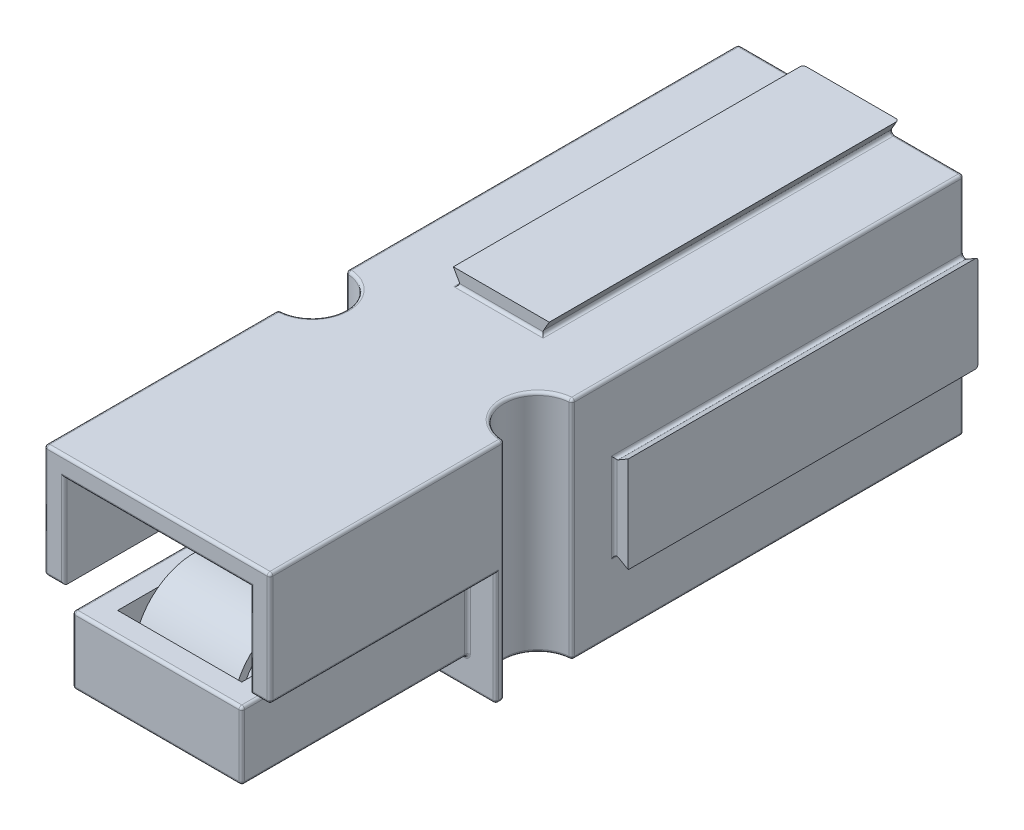
from build123d import *

# Parameters (mm, degrees)
ESQUISSE1_W              = 8.5
ESQUISSE1_H              = 8.5
EXTRUSION1_DEPTH         = 24.6
ESQUISSE6_W              = 3.050497429
ESQUISSE6_H              = 0.5
ESQUISSE6_W_2            = 2.3
ENL_V_MAT_EXTRU_4_DEPTH  = 25.6
ESQUISSE2_W              = 0.5
ESQUISSE2_H              = 2.8
ESQUISSE2_H_2            = 2.3
ENL_V_MAT_EXTRU_1_DEPTH  = 25.6
ESQUISSE4_R              = 1.2
ENL_V_MAT_EXTRU_3_DEPTH  = 9
ESQUISSE11_W             = 3.4
ESQUISSE11_H             = 0.5
ESQUISSE11_W_2           = 0.5
ESQUISSE11_H_2           = 3.4
ENL_V_MAT_EXTRU_9_DEPTH  = 12.2
ENL_V_MAT_EXTRU_5_DEPTH  = 8
ESQUISSE7_W              = 6.6
ESQUISSE7_H              = 3.9
ENL_V_MAT_EXTRU_6_DEPTH  = 8
ESQUISSE8_W              = 5.2
ESQUISSE8_H              = 5.2
ENL_V_MAT_EXTRU_7_DEPTH  = 8
ENL_V_MAT_EXTRU_8_DEPTH  = 13
ENL_V_MAT_EXTRU_10_DEPTH = 12.4
ESQUISSE14_W             = 4.4
ESQUISSE14_H             = 6.4
ENL_V_MAT_EXTRU_11_DEPTH = 1.75
EXTRUSION2_DEPTH         = 1.75
EXTRUSION2_DEPTH_BACK    = 1.75
ESQUISSE15_W             = 4.4
ESQUISSE15_H             = 1.75
ENL_V_MAT_EXTRU_12_DEPTH = 0.8
FILLET1_R                = 0.1
SKETCH1_R                = 2
CUT_EXTRUDE1_DEPTH       = 7.6


with BuildPart() as part:
    # Esquisse1 → Extrusion1 (new body)
    with BuildSketch(Plane.XY):
        Rectangle(ESQUISSE1_W, ESQUISSE1_H)
    extrude(amount=EXTRUSION1_DEPTH)

    # Esquisse6 → Enlèv. mat.-Extru.4 (cut, through all)
    with BuildSketch(Plane.XY.offset(24.6)):
        with Locations((2.975248715, 4)):
            Rectangle(ESQUISSE6_W, ESQUISSE6_H)
        with Locations((-3.1, 4)):
            Rectangle(ESQUISSE6_W_2, ESQUISSE6_H)
    extrude(amount=-ENL_V_MAT_EXTRU_4_DEPTH, mode=Mode.SUBTRACT)

    # Esquisse2 → Enlèv. mat.-Extru.1 (cut, through all)
    with BuildSketch(Plane.XY.offset(24.6)):
        with Locations((4, 2.85)):
            Rectangle(ESQUISSE2_W, ESQUISSE2_H)
        with Locations((4, -3.1)):
            Rectangle(ESQUISSE2_W, ESQUISSE2_H_2)
    extrude(amount=-ENL_V_MAT_EXTRU_1_DEPTH, mode=Mode.SUBTRACT)

    # Esquisse4 → Enlèv. mat.-Extru.3 (cut, through all)
    with BuildSketch(Plane(origin=(0, 3.75, 0), x_dir=(-1, 0, 0), z_dir=(0, 1, 0))):
        with Locations((-3.75, 15.1)):
            Circle(ESQUISSE4_R)
        with Locations((4.25, 15.1)):
            Circle(ESQUISSE4_R)
    extrude(amount=-ENL_V_MAT_EXTRU_3_DEPTH, mode=Mode.SUBTRACT)

    # Esquisse11 → Enlèv. mat.-Extru.9 (cut)
    with BuildSketch(Plane.XY.offset(24.6)):
        with Locations((-0.25, 4)):
            Rectangle(ESQUISSE11_W, ESQUISSE11_H)
        with Locations((4, -0.25)):
            Rectangle(ESQUISSE11_W_2, ESQUISSE11_H_2)
    extrude(amount=-ENL_V_MAT_EXTRU_9_DEPTH, mode=Mode.SUBTRACT)

    # Esquisse5 → Enlèv. mat.-Extru.5 (cut)
    with BuildSketch(Plane.XY.offset(24.6)):
        Polygon((-4.25, -0.25), (-3.25, -0.25), (-3.25, -3.25), (2.75, -3.25), (2.75, -0.25), (3.75, -0.25), (3.75, -4.25), (-4.25, -4.25), align=None)
    extrude(amount=-ENL_V_MAT_EXTRU_5_DEPTH, mode=Mode.SUBTRACT)

    # Esquisse7 → Enlèv. mat.-Extru.6 (cut)
    with BuildSketch(Plane.XY.offset(24.6)):
        with Locations((-0.25, 1.1)):
            Rectangle(ESQUISSE7_W, ESQUISSE7_H)
    extrude(amount=-ENL_V_MAT_EXTRU_6_DEPTH, mode=Mode.SUBTRACT)

    # Esquisse8 → Enlèv. mat.-Extru.7 (cut)
    with BuildSketch(Plane(origin=(0, 0, 0), x_dir=(-1, 0, 0), z_dir=(0, 0, -1))):
        with Locations((0.25, -0.25)):
            Rectangle(ESQUISSE8_W, ESQUISSE8_H)
    extrude(amount=-ENL_V_MAT_EXTRU_7_DEPTH, mode=Mode.SUBTRACT)

    # Esquisse9 → Enlèv. mat.-Extru.8 (cut)
    with BuildSketch(Plane(origin=(0, 0, 0), x_dir=(-1, 0, 0), z_dir=(0, 0, -1))):
        Polygon((-1.45, 4.25), (-1.161324865, 3.75), (-1.45, 3.75), align=None)
        Polygon((1.95, 3.75), (1.95, 4.25), (1.661324865, 3.75), align=None)
        Polygon((-4.25, 1.45), (-3.75, 1.161324865), (-3.75, 1.45), align=None)
        Polygon((-3.75, -1.95), (-4.25, -1.95), (-3.75, -1.661324865), align=None)
    extrude(amount=-ENL_V_MAT_EXTRU_8_DEPTH, mode=Mode.SUBTRACT)

    # Esquisse12 → Enlèv. mat.-Extru.10 (cut)
    with BuildSketch(Plane(origin=(0, 0, 0), x_dir=(-1, 0, 0), z_dir=(0, 0, -1))):
        Polygon((4.25, 1.161324865), (4.25, -1.661324865), (3.75, -1.95), (3.75, 1.45), align=None)
        Polygon((-1.161324865, -4.25), (1.661324865, -4.25), (1.95, -3.75), (-1.45, -3.75), align=None)
    extrude(amount=-ENL_V_MAT_EXTRU_10_DEPTH, mode=Mode.SUBTRACT)

    # Esquisse14 → Enlèv. mat.-Extru.11 (cut)
    with BuildSketch(Plane(origin=(0, -0.85, 0), x_dir=(-1, 0, 0), z_dir=(0, 1, 0))):
        with Locations((0.25, 20.6)):
            Rectangle(ESQUISSE14_W, ESQUISSE14_H)
    extrude(amount=-ENL_V_MAT_EXTRU_11_DEPTH, mode=Mode.SUBTRACT)

    # Esquisse13 → Extrusion2 (add, two sides)
    with BuildSketch(Plane(origin=(-0.25, 0, 0), x_dir=(0, 0, -1), z_dir=(1, 0, 0))) as extrusion2_sk:
        with BuildLine():
            Line((-20.64254699, -0.187518889), (-16.6, -1.320909339))
            Line((-16.6, -1.320909339), (-16.6, -1.632477036))
            Line((-16.6, -1.632477036), (-20.747396642, -0.469690368))
            ThreePointArc((-20.747396642, -0.469690368), (-22.270518835, -0.439467142), (-23.29889814, -1.563411385))
            Line((-23.29889814, -1.563411385), (-23.584023319, -1.470118125))
            ThreePointArc((-23.584023319, -1.470118125), (-22.400977187, -0.169033845), (-20.64254699, -0.187518889))
        make_face()
    extrude(amount=EXTRUSION2_DEPTH)
    extrude(extrusion2_sk.sketch, amount=-EXTRUSION2_DEPTH_BACK)

    # Esquisse15 → Enlèv. mat.-Extru.12 (cut)
    with BuildSketch(Plane.XY.offset(17.4)):
        with Locations((-0.25, -1.725)):
            Rectangle(ESQUISSE15_W, ESQUISSE15_H)
    extrude(amount=-ENL_V_MAT_EXTRU_12_DEPTH, mode=Mode.SUBTRACT)

    # Fillet1
    fillet1_edges = [part.edges().sort_by_distance(p)[0] for p in [
        (1.161324865, -4.25, 6.2),
        (-1.805662433, 4, 0),
        (4, 1.305662433, 0),
        (3.75, -1.661324865, 6.2),
        (4, -1.805662433, 0),
        (-4.25, -0.25, 12.4),
        (2.455662433, -4.25, 0),
        (-4.25, 1.161324865, 6.2),
        (-0.25, -4.25, 12.4),
        (3.75, -4.25, 6.95),
        (-1.661324865, -4.25, 6.2),
        (2.55, -4.25, 15.1),
        (3.75, -4.25, 16.45),
        (-4.25, -4.25, 16.45),
        (-3.05, -4.25, 15.1),
        (-4.25, -4.25, 6.95),
        (-2.955662433, -4.25, 0),
        (-4.25, -1.661324865, 6.2),
        (-4.25, -2.955662433, 0),
        (-4.25, -0.25, 13.9),
        (-4.25, 2.455662433, 0),
        (3.75, 1.75, 24.6),
        (3.75, -0.25, 16.3),
        (-4.25, -0.25, 20.6),
        (-4.25, -0.25, 16.3),
        (-2.955662433, 3.75, 0),
        (2.455662433, 3.75, 0),
        (3.75, 2.455662433, 0),
        (3.75, -2.955662433, 0),
        (-1.661324865, 3.75, 6.2),
        (-4.25, 3.75, 6.95),
        (-3.05, 3.75, 15.1),
        (-4.25, 3.75, 20.45),
        (-0.25, 3.75, 24.6),
        (3.75, 3.75, 20.45),
        (3.75, 3.75, 6.95),
        (3.75, 1.161324865, 6.2),
        (3.75, -0.25, 13.9),
        (2.55, 3.75, 15.1),
        (-0.25, 3.75, 12.4),
        (3.75, -0.25, 12.4),
        (-3.9, -0.25, 24.6),
        (-3.25, -2.05, 24.6),
        (-3.25, -0.85, 20.6),
        (-3.25, -3.25, 20.6),
        (-0.25, -3.25, 24.6),
        (2.75, -3.25, 20.6),
        (2.75, -0.85, 20.6),
        (2.75, -2.05, 24.6),
        (3.4, -0.25, 24.6),
        (3.75, -0.25, 20.6),
        (-4.25, -2.25, 16.6),
        (-0.25, -4.25, 16.6),
        (3.75, -2.25, 16.6),
        (2.75, -2.05, 16.6),
        (-0.25, -3.25, 16.6),
        (-3.25, -2.05, 16.6),
        (-3.55, 1.4, 24.6),
        (3.05, 1.4, 24.6),
        (2.35, -0.85, 16.6),
        (-2.85, -0.85, 16.6),
        (-0.25, -0.85, 24.6),
        (-0.25, 3.05, 24.6),
        (-0.25, 2.35, 0),
        (-2.85, -0.25, 0),
        (-0.25, -2.85, 0),
        (-4.25, 1.75, 24.6),
        (2.35, -0.25, 0),
        (1.161324865, 3.75, 6.2),
        (1.305662433, 4, 0),
    ]]
    fillet(fillet1_edges, radius=FILLET1_R)

    # Sketch1 → Cut-Extrude1 (cut)
    with BuildSketch(Plane(origin=(0, 0, 8), x_dir=(-1, 0, 0), z_dir=(0, 0, -1))):
        with Locations((0.25, -0.25)):
            Circle(SKETCH1_R)
    extrude(amount=-CUT_EXTRUDE1_DEPTH, mode=Mode.SUBTRACT)


solid = part.part
